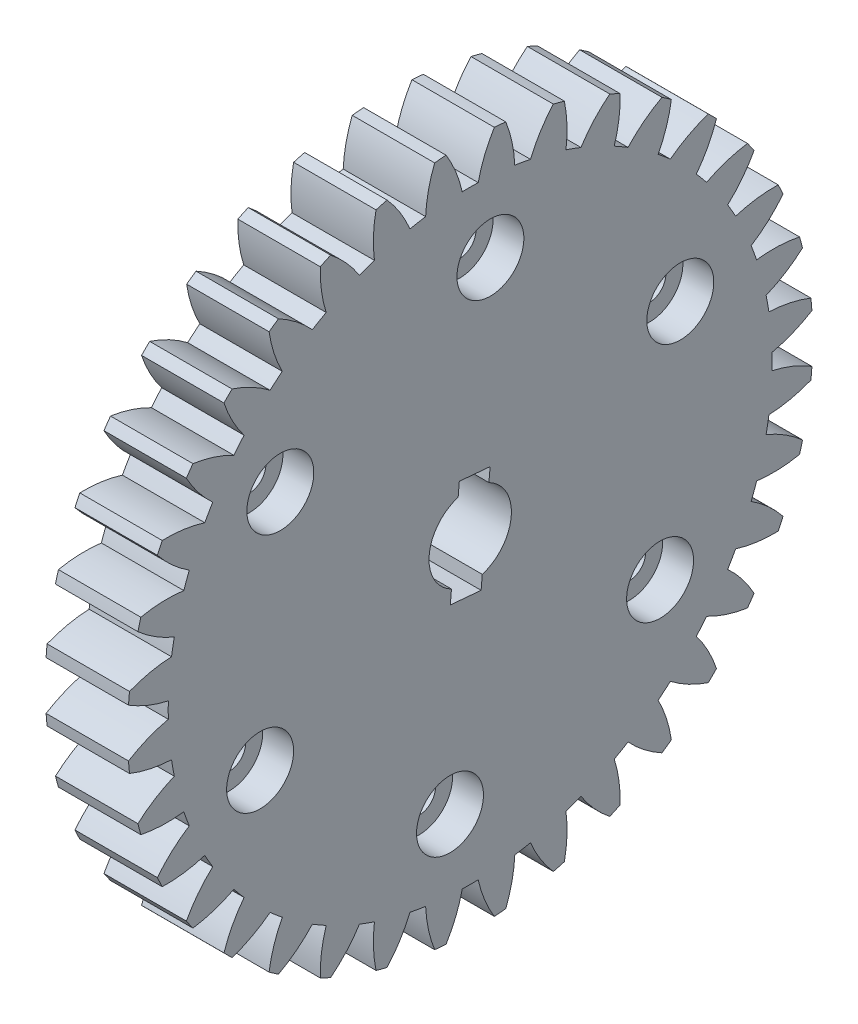
from build123d import *

# Parameters (mm, degrees)
BASPROSKE_W                  = 8
BASPROSKE_H                  = 33.25
TOOTHCUT_DEPTH               = 48.698270409
TEETHCUTS_COUNT              = 36
TEETHCUTS_ANGLE              = 350
BORSKE_R                     = 4
BORE_DEPTH                   = 50.0000508
ESQUISSE2_R                  = 1.6
ENL_V_MAT_EXTRU_2_DEPTH      = 10
ESQUISSE3_R                  = 3.25
ENL_V_MAT_EXTRU_3_DEPTH      = 3
R_P_TITION_CIRCULAIRE1_COUNT = 6
ENL_V_MAT_EXTRU_4_DEPTH      = 10


with BuildPart() as part:
    # BasProSke → Base-Revolve (revolve)
    with BuildSketch(Plane(origin=(0, 0, 0), x_dir=(1, 0, 0), z_dir=(0, 1, 0)), mode=Mode.PRIVATE) as base_revolve_sk:
        with Locations((4, 16.625)):
            Rectangle(BASPROSKE_W, BASPROSKE_H)
    revolve(base_revolve_sk.sketch.rotate(Axis((-10, 0, 0), (1, 0, 0)), 180), axis=Axis((-10, 0, 0), (1, 0, 0)))

    # TooCutSke → ToothCut (cut, through all)
    with BuildSketch(Plane(origin=(0, 0, 0), x_dir=(0, 0, -1), z_dir=(1, 0, 0))):
        with BuildLine():
            ThreePointArc((0.773836769, 29.3012834), (0, 29.3115), (-0.773836769, 29.3012834))
            ThreePointArc((-0.773836769, 29.3012834), (-1.403294931, 31.313012095), (-2.359315682, 33.19165369))
            ThreePointArc((-2.359315682, 33.19165369), (0, 33.2754), (2.359315682, 33.19165369))
            ThreePointArc((2.359315682, 33.19165369), (1.403294931, 31.313012095), (0.773836769, 29.3012834))
        make_face()
    toothcut = extrude(amount=TOOTHCUT_DEPTH, mode=Mode.SUBTRACT)

    # TeethCuts: ToothCut ×36 about axis
    teethcuts_axis = Axis((-10, 0, 0), (1, 0, 0))
    for i in range(1, TEETHCUTS_COUNT):
        add(toothcut.rotate(teethcuts_axis, i * TEETHCUTS_ANGLE / (TEETHCUTS_COUNT - 1)), mode=Mode.SUBTRACT)

    # BorSke → Bore (cut, symmetric)
    with BuildSketch(Plane(origin=(0, 0, 0), x_dir=(0, 0, -1), z_dir=(1, 0, 0))):
        with Locations(Location((0, 0, 0), (0, 0, 180))):
            Circle(BORSKE_R)
    extrude(amount=BORE_DEPTH, both=True, mode=Mode.SUBTRACT)

    # Esquisse2 → Enlèv. mat.-Extru.2 (cut)
    with BuildSketch(Plane(origin=(8, 0, 0), x_dir=(0, 0, -1), z_dir=(1, 0, 0))):
        with Locations((1.961004212, 22.414380707)):
            Circle(ESQUISSE2_R)
    enl_v_mat_extru_2 = extrude(amount=-ENL_V_MAT_EXTRU_2_DEPTH, mode=Mode.SUBTRACT)

    # Esquisse3 → Enlèv. mat.-Extru.3 (cut)
    with BuildSketch(Plane(origin=(8, 0, 0), x_dir=(0, 0, -1), z_dir=(1, 0, 0))):
        with Locations((1.961004212, 22.414380707)):
            Circle(ESQUISSE3_R)
    enl_v_mat_extru_3 = extrude(amount=-ENL_V_MAT_EXTRU_3_DEPTH, mode=Mode.SUBTRACT)

    # Répétition circulaire1: Enlèv. mat.-Extru.2, Enlèv. mat.-Extru.3 ×6 about axis
    r_p_tition_circulaire1_axis = Axis((0, 0, 0), (1, 0, 0))
    add([enl_v_mat_extru_2.rotate(r_p_tition_circulaire1_axis, i * 360 / R_P_TITION_CIRCULAIRE1_COUNT) for i in range(1, R_P_TITION_CIRCULAIRE1_COUNT)], mode=Mode.SUBTRACT)
    add([enl_v_mat_extru_3.rotate(r_p_tition_circulaire1_axis, i * 360 / R_P_TITION_CIRCULAIRE1_COUNT) for i in range(1, R_P_TITION_CIRCULAIRE1_COUNT)], mode=Mode.SUBTRACT)

    # Esquisse4 → Enlèv. mat.-Extru.4 (cut)
    with BuildSketch(Plane(origin=(8, 0, 0), x_dir=(0, 0, -1), z_dir=(1, 0, 0))):
        Polygon((1.058513333, -5.111707105), (-1.930070761, -4.850239876), (-1.058513333, 5.111707105), (1.930070761, 4.850239876), align=None)
    extrude(amount=-ENL_V_MAT_EXTRU_4_DEPTH, mode=Mode.SUBTRACT)


solid = part.part
